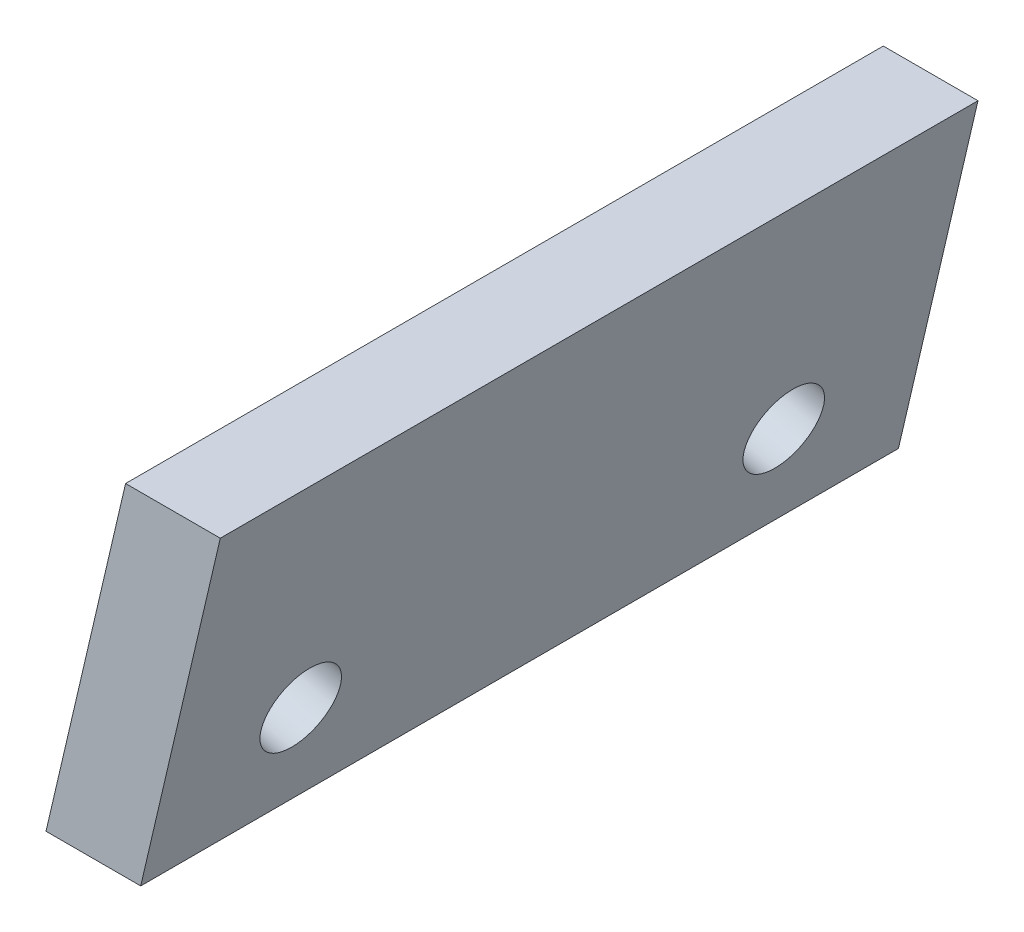
from build123d import *

# Parameters (mm, degrees)
BOSS_EXTRUDE2_DEPTH = 20
SKETCH4_R           = 1.05
CUT_EXTRUDE1_DEPTH  = 5.479855617


with BuildPart() as part:
    # Sketch2 → Boss-Extrude2 (new body)
    with BuildSketch(Plane.XY):
        Polygon((0, 0), (2.5, 0), (4.600215416, 9), (2.100215416, 9), align=None)
    extrude(amount=BOSS_EXTRUDE2_DEPTH)

    # Sketch4 → Cut-Extrude1 (cut, through all)
    with BuildSketch(Plane(origin=(0, 0, 0), x_dir=(0, 0, 1), z_dir=(-0.973836052, 0.227251721, 0))):
        with Locations((3.625, 3.2)):
            Circle(SKETCH4_R)
        with Locations((16.375, 3.2)):
            Circle(SKETCH4_R)
    extrude(amount=-CUT_EXTRUDE1_DEPTH, mode=Mode.SUBTRACT)


solid = part.part
